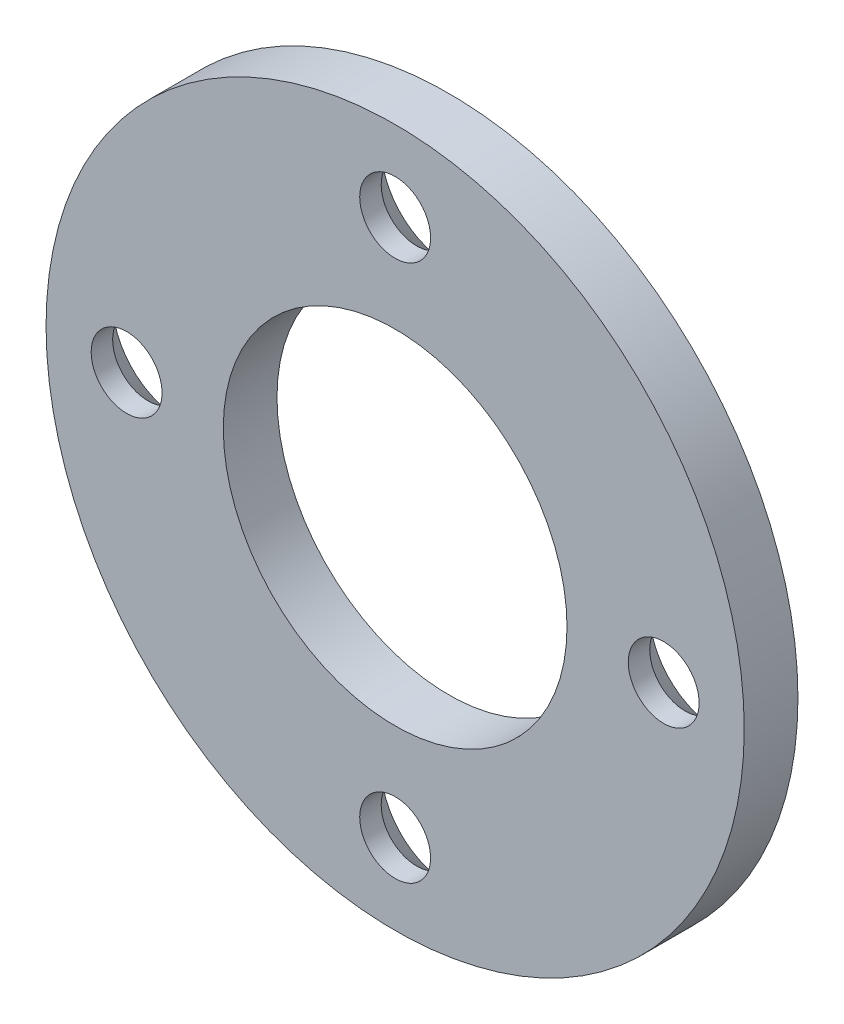
from build123d import *

# Parameters (mm, degrees)
ESQUISSE1_R                  = 32.5
BOSS_EXTRU_1_DEPTH           = 5
R_P_TITION_CIRCULAIRE1_COUNT = 4
ESQUISSE2_R                  = 16
ENL_V_MAT_EXTRU_1_DEPTH      = 6


with BuildPart() as part:
    # Esquisse1 → Boss.-Extru.1 (new body)
    with BuildSketch(Plane.XY):
        Circle(ESQUISSE1_R)
    extrude(amount=BOSS_EXTRU_1_DEPTH)

    # Esquisse5 → Fraisage pour vis à tête fraisée M61 (revolve, cut)
    with BuildSketch(Plane(origin=(0, -25, 0), x_dir=(0, 1, 0), z_dir=(1, 0, 0))):
        Polygon((0, 0), (0, 5), (3.3, 5), (3.3, 3), (6.3, 0), align=None)
    fraisage_pour_vis_t_te_frais_e_m61 = revolve(axis=Axis((0, -25, -6.35), (0, 0, 1)), mode=Mode.SUBTRACT)

    # Répétition circulaire1: Fraisage pour vis à tête fraisée M61 ×4 about axis
    r_p_tition_circulaire1_axis = Axis((0, 0, 0), (0, 0, 1))
    for i in range(1, R_P_TITION_CIRCULAIRE1_COUNT):
        add(fraisage_pour_vis_t_te_frais_e_m61.rotate(r_p_tition_circulaire1_axis, i * 360 / R_P_TITION_CIRCULAIRE1_COUNT), mode=Mode.SUBTRACT)

    # Esquisse2 → Enlèv. mat.-Extru.1 (cut, through all)
    with BuildSketch(Plane.XY.offset(5)):
        Circle(ESQUISSE2_R)
    extrude(amount=-ENL_V_MAT_EXTRU_1_DEPTH, mode=Mode.SUBTRACT)


solid = part.part
